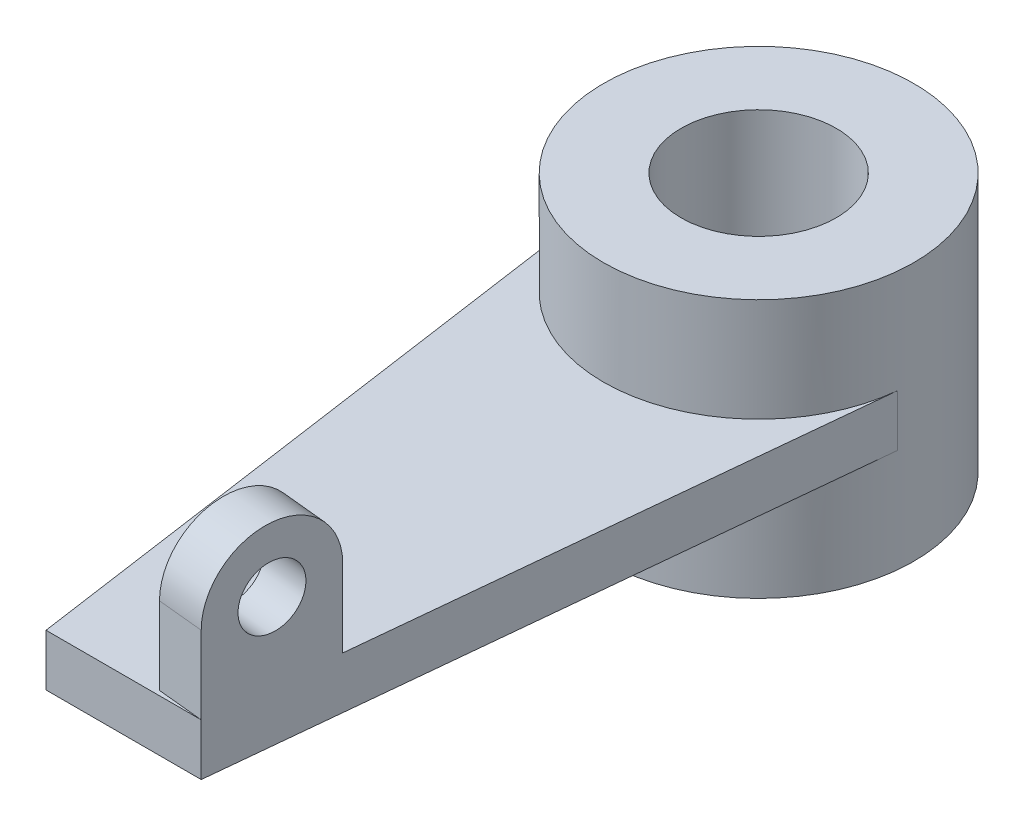
from build123d import *

# Parameters (mm, degrees)
SKETCH9_R           = 30
SKETCH9_R_2         = 15
BOSS_EXTRUDE4_DEPTH = 25
BOSS_EXTRUDE5_DEPTH = 5
CUT_EXTRUDE2_DEPTH  = 99
SKETCH12_R          = 6
BOSS_EXTRUDE6_DEPTH = 9


with BuildPart() as part:
    # Sketch9 → Boss-Extrude4 (new body, symmetric)
    with BuildSketch(Plane(origin=(0, 0, 0), x_dir=(1, 0, 0), z_dir=(0, 1, 0))):
        Circle(SKETCH9_R)
        Circle(SKETCH9_R_2, mode=Mode.SUBTRACT)
    extrude(amount=BOSS_EXTRUDE4_DEPTH, both=True)

    # Sketch10 → Boss-Extrude5 (add, symmetric)
    with BuildSketch(Plane(origin=(0, 0, 0), x_dir=(1, 0, 0), z_dir=(0, 1, 0))):
        Polygon((29.859037173, -2.904806205), (17.655167851, -125.404806205), (-12.344832149, -125.404806205), (-29.859037173, -2.904806205), align=None)
    extrude(amount=BOSS_EXTRUDE5_DEPTH, both=True)

    # Sketch11 → Cut-Extrude2 (cut)
    with BuildSketch(Plane(origin=(0, 5, 0), x_dir=(1, 0, 0), z_dir=(0, 1, 0))):
        with BuildLine():
            Line((-14.716049093, -2.904806205), (14.716049093, -2.904806205))
            ThreePointArc((14.716049093, -2.904806205), (0, -15), (-14.716049093, -2.904806205))
        make_face()
    extrude(amount=-CUT_EXTRUDE2_DEPTH, mode=Mode.SUBTRACT)

    # Sketch12 → Boss-Extrude6 (add)
    with BuildSketch(Plane(origin=(29.852146538, 0, 2.973973023), x_dir=(0.0991327, 0, -0.995074222), z_dir=(0.995074222, 0, 0.0991327))):
        with BuildLine():
            Line((-123.036885537, 20), (-123.036885537, 5))
            Line((-123.036885537, 5), (-98.036885537, 5))
            Line((-98.036885537, 5), (-98.036885537, 20))
            ThreePointArc((-98.036885537, 20), (-110.536885537, 32.5), (-123.036885537, 20))
        make_face()
        with Locations((-110.536885537, 20)):
            Circle(SKETCH12_R, mode=Mode.SUBTRACT)
    extrude(amount=-BOSS_EXTRUDE6_DEPTH)


solid = part.part
